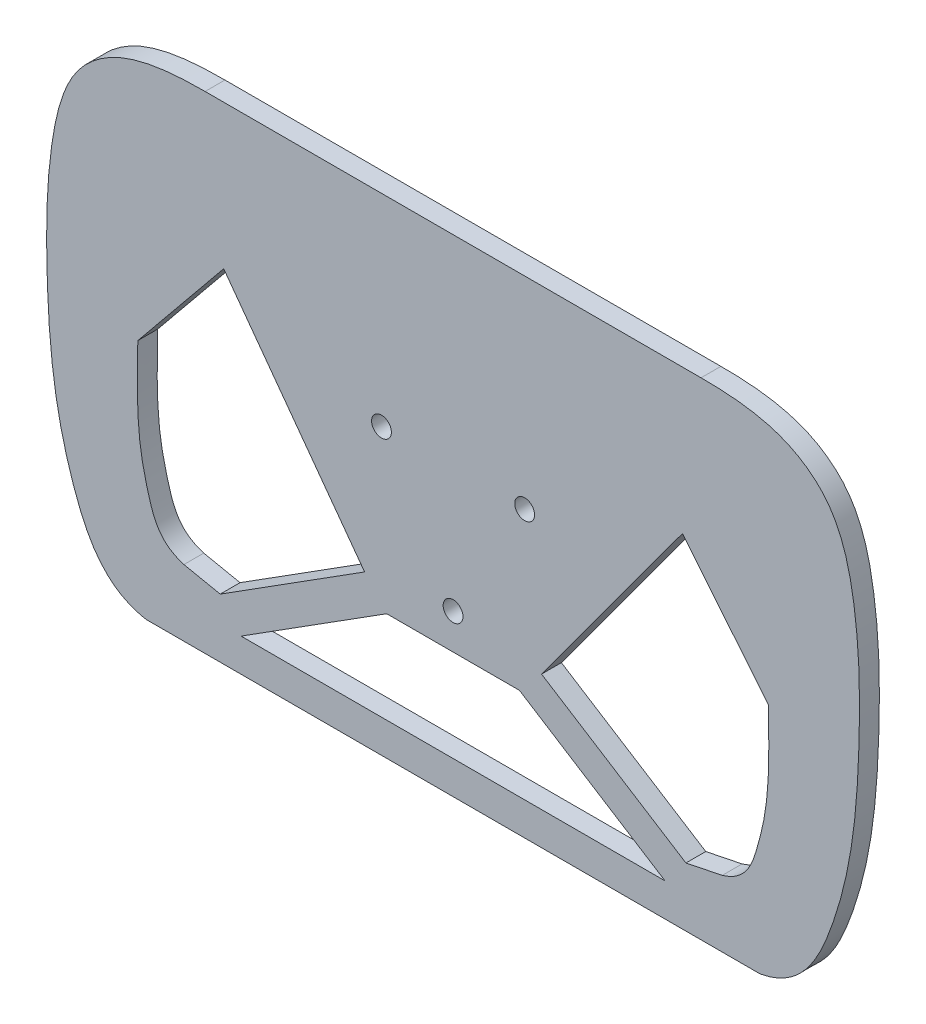
from build123d import *

# Parameters (mm, degrees)
SKETCH1_R           = 3
BOSS_EXTRUDE1_DEPTH = 6


with BuildPart() as part:
    # Sketch1 → Boss-Extrude1 (new body)
    with BuildSketch(Plane.XY):
        with BuildLine():
            Line((92.841871249, -73.620070941), (-92.841871249, -73.620070941))
            add(Edge.make_bspline(
                [(-75, 73.592558307), (-82.684370337, 73.592558307), (-97.854658076, 72.84953562), (-116.58129419, 59.781757802), (-122.878964083, 33.919509961), (-123.235734842, 4.232494838), (-121.42217592, -25.830232168), (-114.384033914, -53.876688185), (-105.21357221, -71.413623273), (-92.841871249, -73.620070941)],
                knots=[0, 0, 0, 0, 0.136998407, 0.217327042, 0.350867913, 0.535494521, 0.700007308, 0.828084137, 1, 1, 1, 1], degree=3))
            Line((-75, 73.592558307), (75, 73.592558307))
            add(Edge.make_bspline(
                [(75, 73.592558307), (82.684370337, 73.592558307), (97.854658076, 72.84953562), (116.58129419, 59.781757802), (122.878964083, 33.919509961), (123.235734842, 4.232494838), (121.42217592, -25.830232168), (114.384033914, -53.876688185), (105.21357221, -71.413623273), (92.841871249, -73.620070941)],
                knots=[0, 0, 0, 0, 0.136998407, 0.217327042, 0.350867913, 0.535494521, 0.700007308, 0.828084137, 1, 1, 1, 1], degree=3))
        make_face()
        with Locations((-21.650635095, 12.5)):
            Circle(SKETCH1_R, mode=Mode.SUBTRACT)
        with Locations((21.650635095, 12.5)):
            Circle(SKETCH1_R, mode=Mode.SUBTRACT)
        with Locations((0, -25)):
            Circle(SKETCH1_R, mode=Mode.SUBTRACT)
        with BuildLine():
            Line((69.370032777, 29.977750595), (95.356248747, -1.843539004))
            add(Edge.make_bspline(
                [(95.356248747, -1.843539004), (95.671527316, -16.555540014), (95.495129896, -27.347253955), (91.456528801, -43.448489839), (88.616577504, -51.376366499), (81.407786651, -53.527589513)],
                knots=[0, 0, 0, 0, 0.501052944, 0.6781501, 1, 1, 1, 1], degree=3))
            Line((81.407786651, -53.527589513), (70.423019625, -55.77404363))
            Line((70.423019625, -55.77404363), (26.760379335, -28.138662852))
            Line((26.760379335, -28.138662852), (69.370032777, 29.977750595))
        make_face(mode=Mode.SUBTRACT)
        Polygon((-20.070368486, -35.739051104), (20.070368486, -35.739051104), (64.121107278, -63.620070941), (-64.121107278, -63.620070941), align=None, mode=Mode.SUBTRACT)
        with BuildLine():
            Line((-69.370032777, 29.977750595), (-95.356248747, -1.843539004))
            add(Edge.make_bspline(
                [(-95.356248747, -1.843539004), (-95.671527316, -16.555540014), (-95.495129896, -27.347253955), (-91.456528801, -43.448489839), (-88.616577504, -51.376366499), (-81.407786651, -53.527589513)],
                knots=[0, 0, 0, 0, 0.501052944, 0.6781501, 1, 1, 1, 1], degree=3))
            Line((-81.407786651, -53.527589513), (-70.423019625, -55.77404363))
            Line((-70.423019625, -55.77404363), (-26.760379335, -28.138662852))
            Line((-26.760379335, -28.138662852), (-69.370032777, 29.977750595))
        make_face(mode=Mode.SUBTRACT)
    extrude(amount=BOSS_EXTRUDE1_DEPTH)


solid = part.part
